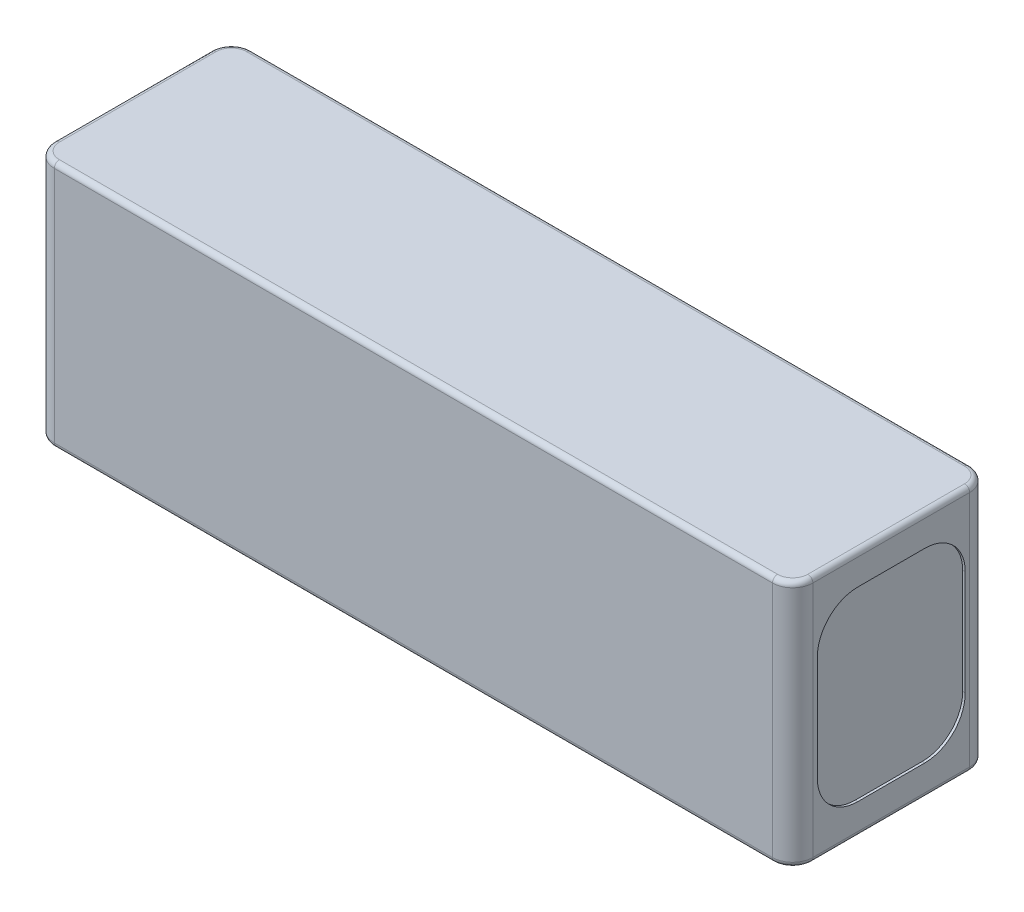
from build123d import *

# Parameters (mm, degrees)
SKETCH1_W           = 150
SKETCH1_H           = 49
BOSS_EXTRUDE1_DEPTH = 39
CUT_EXTRUDE1_DEPTH  = 0.5
CUT_EXTRUDE2_DEPTH  = 0.5
FILLET1_R           = 4
FILLET2_R           = 1


with BuildPart() as part:
    # Sketch1 → Boss-Extrude1 (new body)
    with BuildSketch(Plane(origin=(0, 0, -15), x_dir=(-1, 0, 0), z_dir=(0, 0, -1))):
        with Locations((6, 2.5)):
            Rectangle(SKETCH1_W, SKETCH1_H)
    extrude(amount=-BOSS_EXTRUDE1_DEPTH)

    # Sketch2 → Cut-Extrude1 (cut)
    with BuildSketch(Plane(origin=(69, 0, 0), x_dir=(0, 0, -1), z_dir=(1, 0, 0))):
        with BuildLine():
            Line((-19.125, 12.875), (-19.125, -7.875))
            ThreePointArc((-19.125, -7.875), (-16.781854249, -13.531854249), (-11.125, -15.875))
            Line((-11.125, -15.875), (2.125, -15.875))
            ThreePointArc((2.125, -15.875), (7.781854249, -13.531854249), (10.125, -7.875))
            Line((10.125, -7.875), (10.125, 12.875))
            ThreePointArc((10.125, 12.875), (7.781854249, 18.531854249), (2.125, 20.875))
            Line((2.125, 20.875), (-11.125, 20.875))
            ThreePointArc((-11.125, 20.875), (-16.781854249, 18.531854249), (-19.125, 12.875))
        make_face()
    extrude(amount=-CUT_EXTRUDE1_DEPTH, mode=Mode.SUBTRACT)

    # Sketch3 → Cut-Extrude2 (cut)
    with BuildSketch(Plane.ZY.offset(81)):
        with BuildLine():
            Line((11.125, 20.875), (-2.125, 20.875))
            ThreePointArc((-2.125, 20.875), (-7.781854249, 18.531854249), (-10.125, 12.875))
            Line((-10.125, 12.875), (-10.125, -7.875))
            ThreePointArc((-10.125, -7.875), (-7.781854249, -13.531854249), (-2.125, -15.875))
            Line((-2.125, -15.875), (11.125, -15.875))
            ThreePointArc((11.125, -15.875), (16.781854249, -13.531854249), (19.125, -7.875))
            Line((19.125, -7.875), (19.125, 12.875))
            ThreePointArc((19.125, 12.875), (16.781854249, 18.531854249), (11.125, 20.875))
        make_face()
    extrude(amount=-CUT_EXTRUDE2_DEPTH, mode=Mode.SUBTRACT)

    # Fillet1
    fillet1_edges = [part.edges().sort_by_distance(p)[0] for p in [
        (-81, 2.5, 24),
        (69, 2.5, 24),
        (-81, 2.5, -15),
        (69, 2.5, -15),
    ]]
    fillet(fillet1_edges, radius=FILLET1_R)

    # Fillet2
    fillet2_edges = [part.edges().sort_by_distance(p)[0] for p in [
        (-6, -22, -15),
        (-6, 27, -15),
        (-81, 27, 4.5),
        (-6, 27, 24),
        (69, 27, 4.5),
        (67.828427125, 27, 22.828427125),
        (67.828427125, 27, -13.828427125),
        (-79.828427125, 27, 22.828427125),
        (-79.828427125, 27, -13.828427125),
        (-81, -22, 4.5),
        (69, -22, 4.5),
        (-6, -22, 24),
        (67.828427125, -22, 22.828427125),
        (67.828427125, -22, -13.828427125),
        (-79.828427125, -22, 22.828427125),
        (-79.828427125, -22, -13.828427125),
    ]]
    fillet(fillet2_edges, radius=FILLET2_R)


solid = part.part
